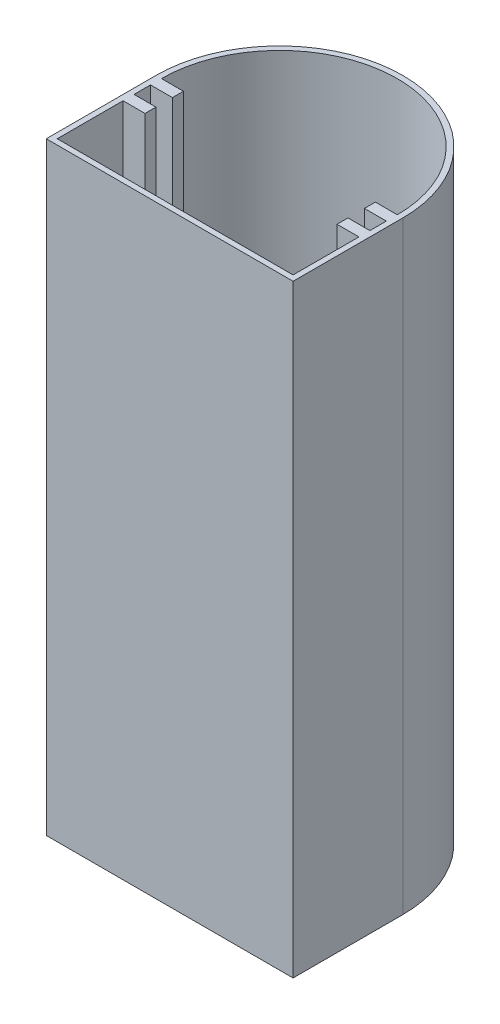
from build123d import *

# Parameters (mm, degrees)
BOSS_EXTRUDE1_DEPTH = 110
CUT_EXTRUDE1_DEPTH  = 109
SKETCH3_R           = 2.875
CUT_EXTRUDE2_DEPTH  = 5


with BuildPart() as part:
    # Sketch1 → Boss-Extrude1 (new body)
    with BuildSketch(Plane(origin=(0, 0, 0), x_dir=(1, 0, 0), z_dir=(0, 1, 0))):
        with BuildLine():
            Line((-43.883093525, -1.707733813), (1.116906475, -1.707733813))
            Line((1.116906475, -1.707733813), (1.116906475, 18.292266187))
            ThreePointArc((1.116906475, 18.292266187), (-21.383093525, 40.792266187), (-43.883093525, 18.292266187))
            Line((-43.883093525, 18.292266187), (-43.883093525, -1.707733813))
        make_face()
    extrude(amount=BOSS_EXTRUDE1_DEPTH)

    # Sketch2 → Cut-Extrude1 (cut)
    with BuildSketch(Plane(origin=(0, 110, 0), x_dir=(1, 0, 0), z_dir=(0, 1, 0))):
        with BuildLine():
            Line((-42.883093525, 16.292266187), (-42.883093525, 13.292266187))
            Line((-42.883093525, 13.292266187), (-38.883093525, 13.292266187))
            Line((-38.883093525, 13.292266187), (-38.883093525, 11.292266187))
            Line((-38.883093525, 11.292266187), (-42.883093525, 11.292266187))
            Line((-42.883093525, 11.292266187), (-42.883093525, -0.707733813))
            Line((-42.883093525, -0.707733813), (0.116906475, -0.707733813))
            Line((0.116906475, -0.707733813), (0.116906475, 11.292266187))
            Line((0.116906475, 11.292266187), (-3.883093525, 11.292266187))
            Line((-3.883093525, 11.292266187), (-3.883093525, 13.292266187))
            Line((-3.883093525, 13.292266187), (0.116906475, 13.292266187))
            Line((0.116906475, 13.292266187), (0.116906475, 16.292266187))
            Line((0.116906475, 16.292266187), (-3.883093525, 16.292266187))
            Line((-3.883093525, 16.292266187), (-3.883093525, 18.292266187))
            Line((-3.883093525, 18.292266187), (0.116906475, 18.292266187))
            ThreePointArc((0.116906475, 18.292266187), (-21.383093525, 39.792266187), (-42.883093525, 18.292266187))
            Line((-42.883093525, 18.292266187), (-38.883093525, 18.292266187))
            Line((-38.883093525, 18.292266187), (-38.883093525, 16.292266187))
            Line((-38.883093525, 16.292266187), (-42.883093525, 16.292266187))
        make_face()
    extrude(amount=-CUT_EXTRUDE1_DEPTH, mode=Mode.SUBTRACT)

    # Sketch3 → Cut-Extrude2 (cut)
    with BuildSketch(Plane.ZY.offset(43.883093525)):
        with Locations((-4.958932854, 55)):
            Circle(SKETCH3_R)
    extrude(amount=-CUT_EXTRUDE2_DEPTH, mode=Mode.SUBTRACT)


solid = part.part
